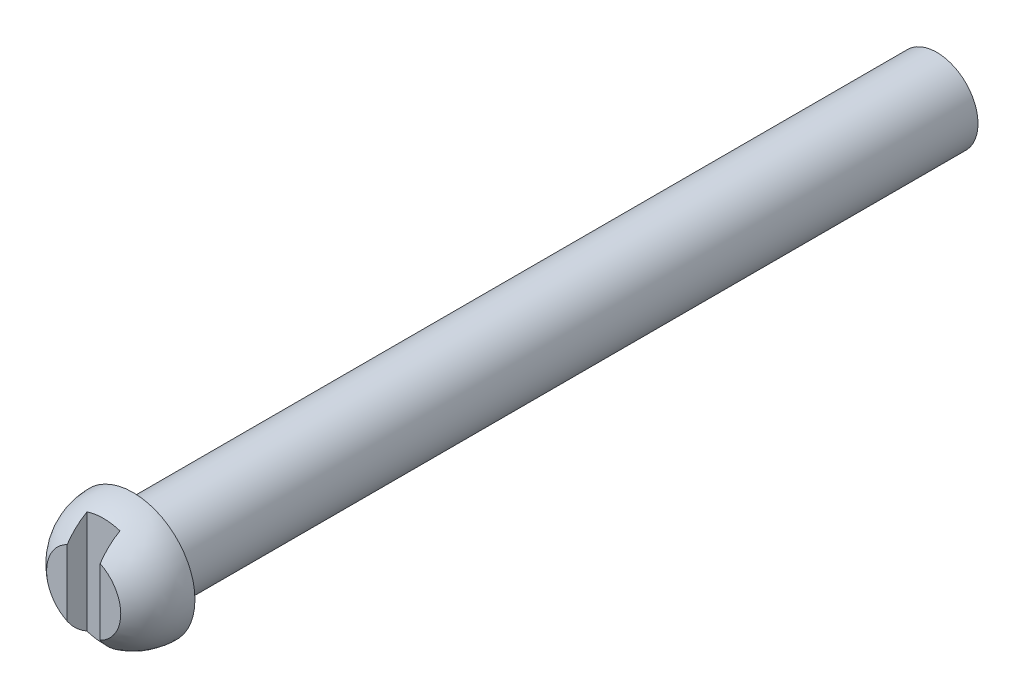
from build123d import *

# Parameters (mm, degrees)
BOSS_EXTRUDE1_DEPTH      = 15.875
BOSS_EXTRUDE1_DEPTH_BACK = 46.0375
SKETCH1_R                = 3.175
REVOLVE1_ANGLE           = 180
CUT_EXTRUDE1_DEPTH       = 8.382
CUT_EXTRUDE1_DEPTH_BACK  = 9.398
SKETCH3_W                = 2.54
SKETCH3_H                = 12.7
SKETCH4_W                = 2.54
SKETCH4_H                = 12.81199514
CUT_EXTRUDE2_DEPTH       = 1.524


with BuildPart() as part:
    # Sketch1 → Boss-Extrude1 (new, two sides: drawn at the far end of the back side and taken through both)
    with BuildSketch(Plane.XY.offset(-BOSS_EXTRUDE1_DEPTH_BACK)):
        Circle(SKETCH1_R)
    extrude(amount=BOSS_EXTRUDE1_DEPTH + BOSS_EXTRUDE1_DEPTH_BACK)

    # Sketch2 → Revolve1 (revolve)
    with BuildSketch(Plane.XY.offset(15.875)):
        with BuildLine():
            Line((0, -4.7625), (0, 4.7625))
            ThreePointArc((0, 4.7625), (4.7625, 0), (0, -4.7625))
        make_face()
    revolve(axis=Axis((0, -4.7625, 15.875), (0, -1, 0)), revolution_arc=REVOLVE1_ANGLE)

    # Sketch3 → Cut-Extrude1 (cut, two sides: drawn at the far end of the back side and taken through both)
    with BuildSketch(Plane(origin=(2.54, 0, 0), x_dir=(0, 0, -1), z_dir=(1, 0, 0)).offset(-CUT_EXTRUDE1_DEPTH_BACK)):
        with Locations((-20.955, -1.5875)):
            Rectangle(SKETCH3_W, SKETCH3_H)
    extrude(amount=CUT_EXTRUDE1_DEPTH + CUT_EXTRUDE1_DEPTH_BACK, mode=Mode.SUBTRACT)

    # Sketch4 → Cut-Extrude2 (cut)
    with BuildSketch(Plane.XY.offset(19.685)):
        with Locations((0, -0.792879604)):
            Rectangle(SKETCH4_W, SKETCH4_H)
    extrude(amount=-CUT_EXTRUDE2_DEPTH, mode=Mode.SUBTRACT)


solid = part.part
